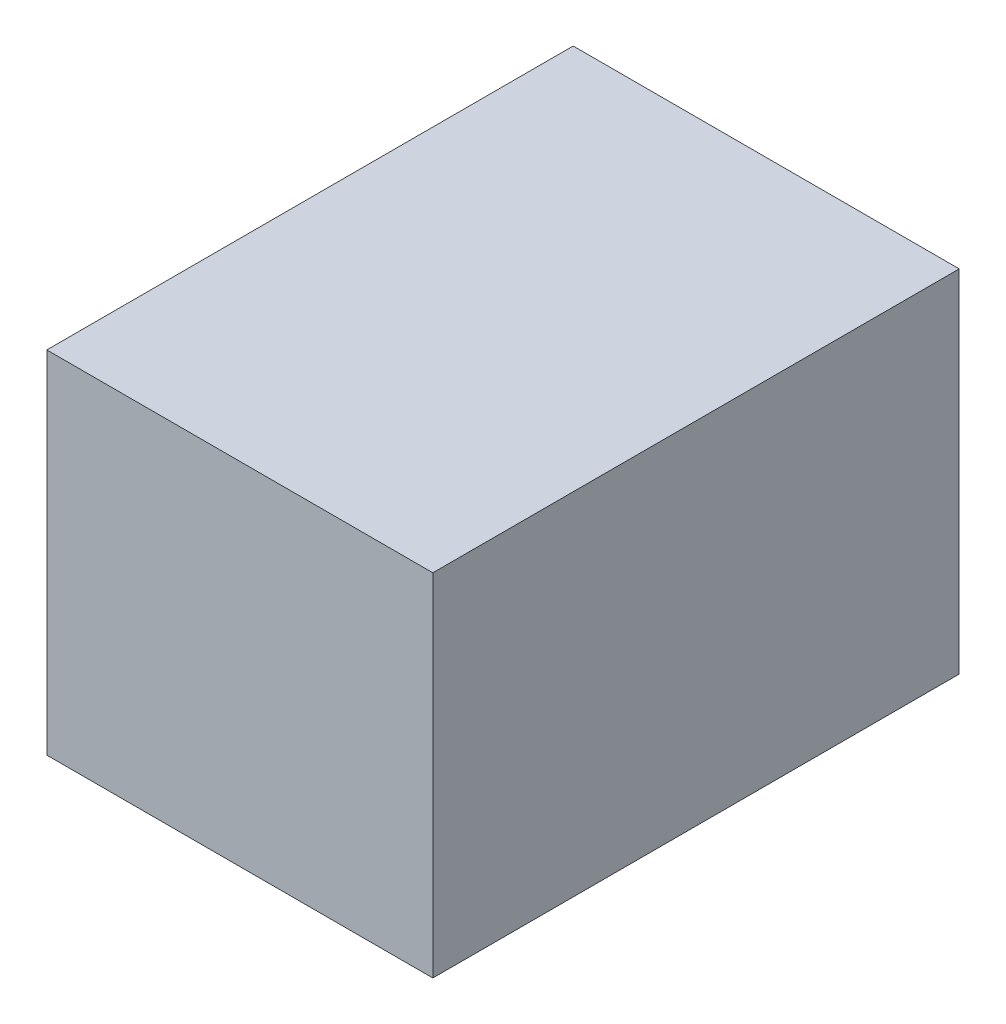
from build123d import *

# Parameters (mm, degrees)
SKETCH1_W           = 11
SKETCH1_H           = 15
BOSS_EXTRUDE1_DEPTH = 10


with BuildPart() as part:
    # Sketch1 → Boss-Extrude1 (new body)
    with BuildSketch(Plane(origin=(0, 0, 0), x_dir=(1, 0, 0), z_dir=(0, 1, 0))):
        with Locations((9.784562046, -14.163770472)):
            Rectangle(SKETCH1_W, SKETCH1_H)
    extrude(amount=BOSS_EXTRUDE1_DEPTH)


solid = part.part
